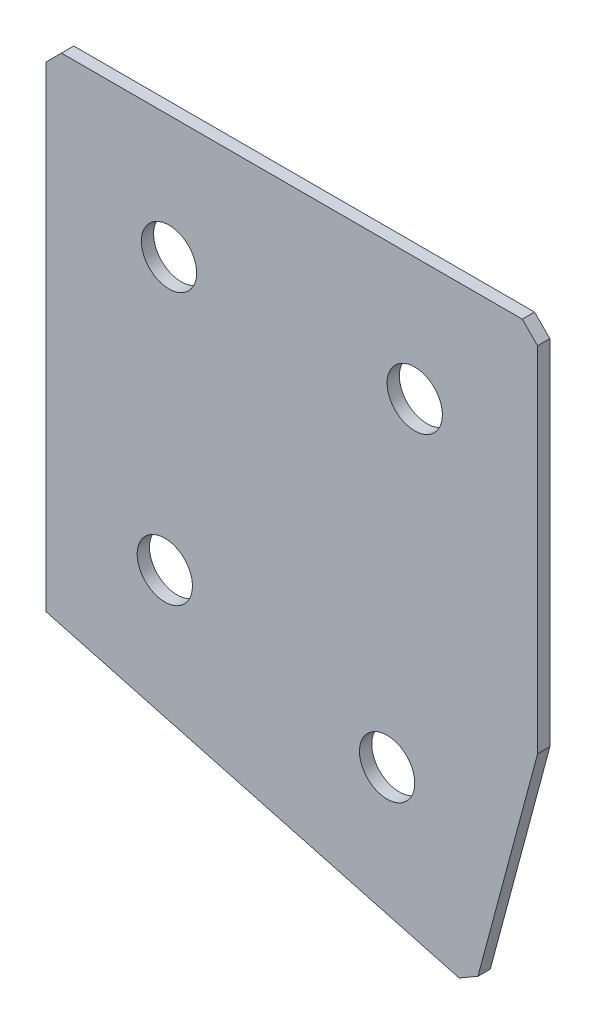
from build123d import *

# Parameters (mm, degrees)
EXTRUDE_1_DEPTH   = 2
HOLE_WIZARD_M81_D = 9
CHAMFER_1_SIZE    = 2.5


with BuildPart() as part:
    # Эскиз3 → Бобышка-Вытянуть1 (new body)
    with BuildSketch(Plane(origin=(0, 0, 0), x_dir=(1, 0, 0), z_dir=(0, 0, -1))):
        Polygon((0, 0), (80, 0), (80, 60.024888178), (69.647238196, 98.66192123), (0, 80), align=None)
    extrude(amount=EXTRUDE_1_DEPTH)

    # Отверстие с зазором M81 (through all)
    with Locations(Plane(origin=(0, 0, -2), x_dir=(1, 0, 0), z_dir=(0, 0, -1))):
        with Locations((20, 20), (60, 20), (19.318516526, 64.470857294), (55.505102572, 74.167023802)):
            Hole(HOLE_WIZARD_M81_D / 2)

    # Фаска1
    chamfer_1_edges = [part.edges().sort_by_distance(p)[0] for p in [
        (69.647238196, -98.66192123, -1),
        (80, 0, -1),
        (0, 0, -1),
    ]]
    chamfer(chamfer_1_edges, length=CHAMFER_1_SIZE)


solid = part.part
